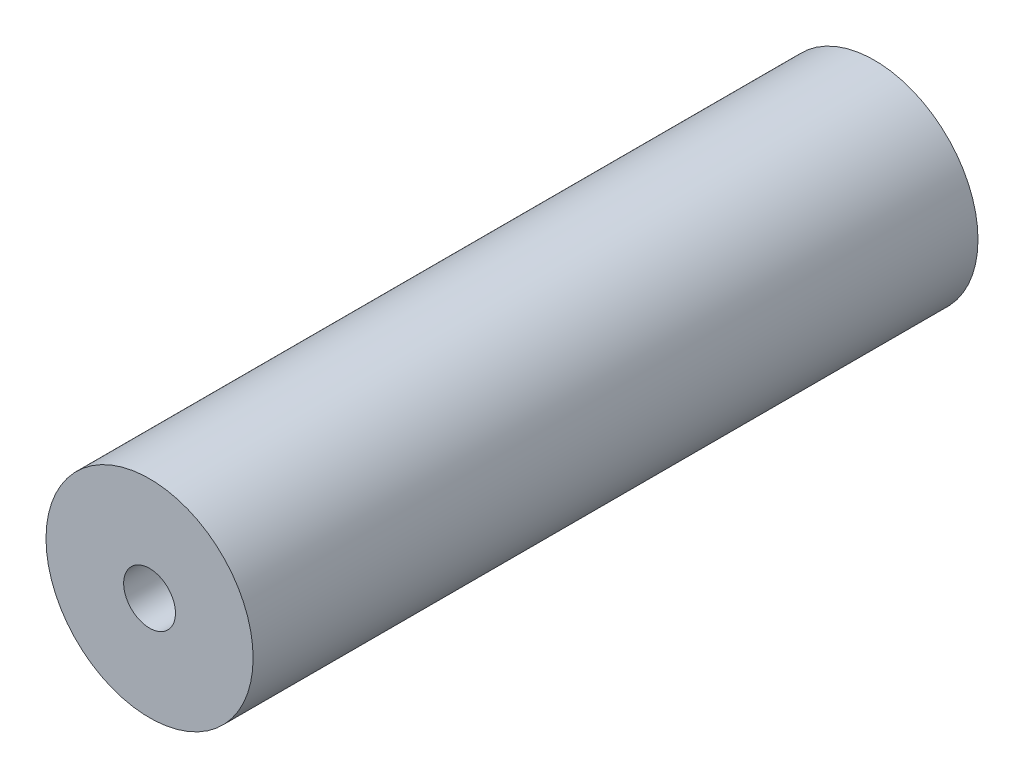
from build123d import *

# Parameters (mm, degrees)
SKETCH1_R           = 25.4
SKETCH1_R_2         = 6.35
BOSS_EXTRUDE1_DEPTH = 177.8


with BuildPart() as part:
    # Sketch1 → Boss-Extrude1 (new body)
    with BuildSketch(Plane.XY):
        Circle(SKETCH1_R)
        Circle(SKETCH1_R_2, mode=Mode.SUBTRACT)
    extrude(amount=BOSS_EXTRUDE1_DEPTH)


solid = part.part
